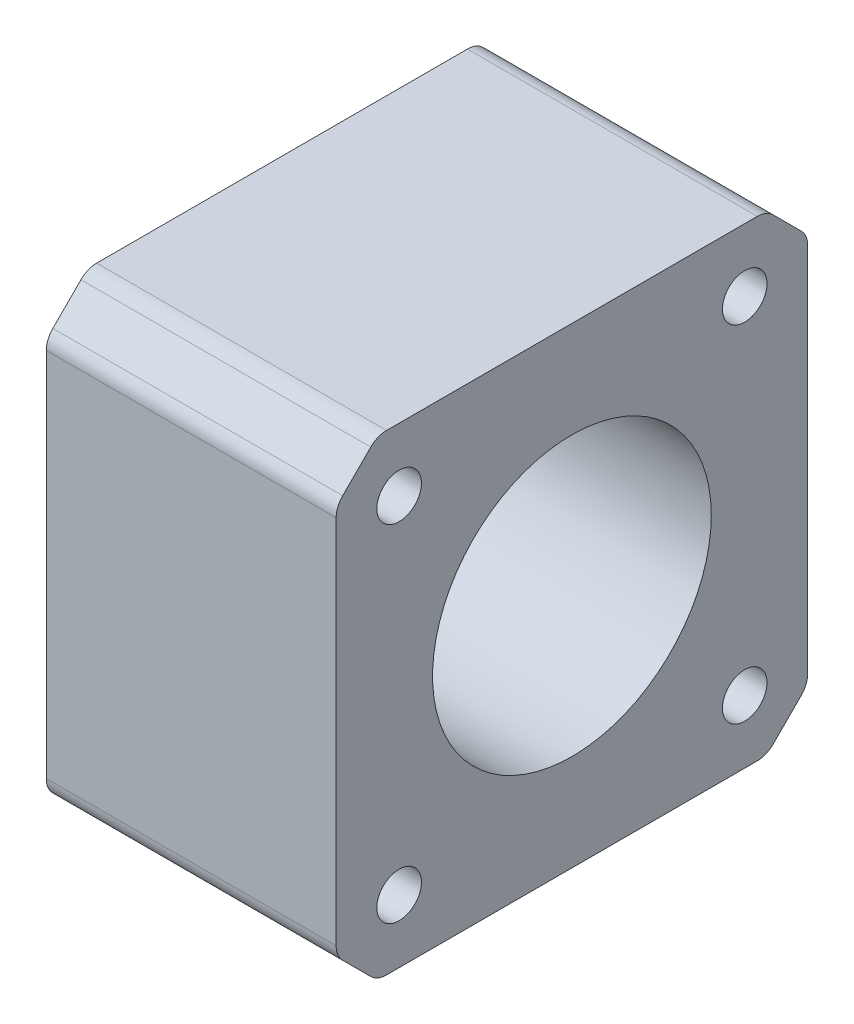
from build123d import *

# Parameters (mm, degrees)
BOSS_EXTRUDE1_DEPTH     = 26
FILLET1_R               = 2
SKETCH2_R               = 12.5
CUT_EXTRUDE1_DEPTH      = 27
SKETCH3_R               = 2
CUT_EXTRUDE2_DEPTH      = 27
LPATTERN1_COUNT         = 2
LPATTERN1_PITCH         = 31
MIRROR1_COPY_1_SKETCH_R = 2
MIRROR1_COPY_1_DEPTH    = 27


with BuildPart() as part:
    # Sketch1 → Boss-Extrude1 (new body)
    with BuildSketch(Plane(origin=(0, 0, 0), x_dir=(0, 0, -1), z_dir=(1, 0, 0))):
        Polygon((-21.15, 17.458030253), (-17.458030253, 21.15), (17.458030253, 21.15), (21.15, 17.458030253), (21.15, -17.458030253), (17.458030253, -21.15), (-17.458030253, -21.15), (-21.15, -17.458030253), align=None)
    extrude(amount=BOSS_EXTRUDE1_DEPTH)

    # Fillet1
    fillet1_edges = [part.edges().sort_by_distance(p)[0] for p in [
        (13, 17.458030253, 21.15),
        (13, 21.15, 17.458030253),
        (13, 21.15, -17.458030253),
        (13, 17.458030253, -21.15),
        (13, -17.458030253, -21.15),
        (13, -21.15, -17.458030253),
        (13, -21.15, 17.458030253),
        (13, -17.458030253, 21.15),
    ]]
    fillet(fillet1_edges, radius=FILLET1_R)

    # Sketch2 → Cut-Extrude1 (cut, through all)
    with BuildSketch(Plane(origin=(26, 0, 0), x_dir=(0, 0, -1), z_dir=(1, 0, 0))):
        Circle(SKETCH2_R)
    extrude(amount=-CUT_EXTRUDE1_DEPTH, mode=Mode.SUBTRACT)

    # Sketch3 → Cut-Extrude2 (cut, through all)
    with BuildSketch(Plane(origin=(26, 0, 0), x_dir=(0, 0, -1), z_dir=(1, 0, 0))):
        with Locations((-15.5, 15.5)):
            Circle(SKETCH3_R)
    cut_extrude2 = extrude(amount=-CUT_EXTRUDE2_DEPTH, mode=Mode.SUBTRACT)

    # LPattern1: Cut-Extrude2 ×2
    with Locations(*[(0, 0, -i * LPATTERN1_PITCH) for i in range(1, LPATTERN1_COUNT)]):
        add(cut_extrude2, mode=Mode.SUBTRACT)

    # Mirror1: Cut-Extrude2 across plane
    add(cut_extrude2.mirror(Plane.ZX), mode=Mode.SUBTRACT)

    # Mirror1 copy 1 sketch → Mirror1 copy 1 (cut, through all)
    with BuildSketch(Plane(origin=(26, 0, -31), x_dir=(0, 0, -1), z_dir=(1, 0, 0))):
        with Locations((-15.5, -15.5)):
            Circle(MIRROR1_COPY_1_SKETCH_R)
    extrude(amount=-MIRROR1_COPY_1_DEPTH, mode=Mode.SUBTRACT)


solid = part.part
